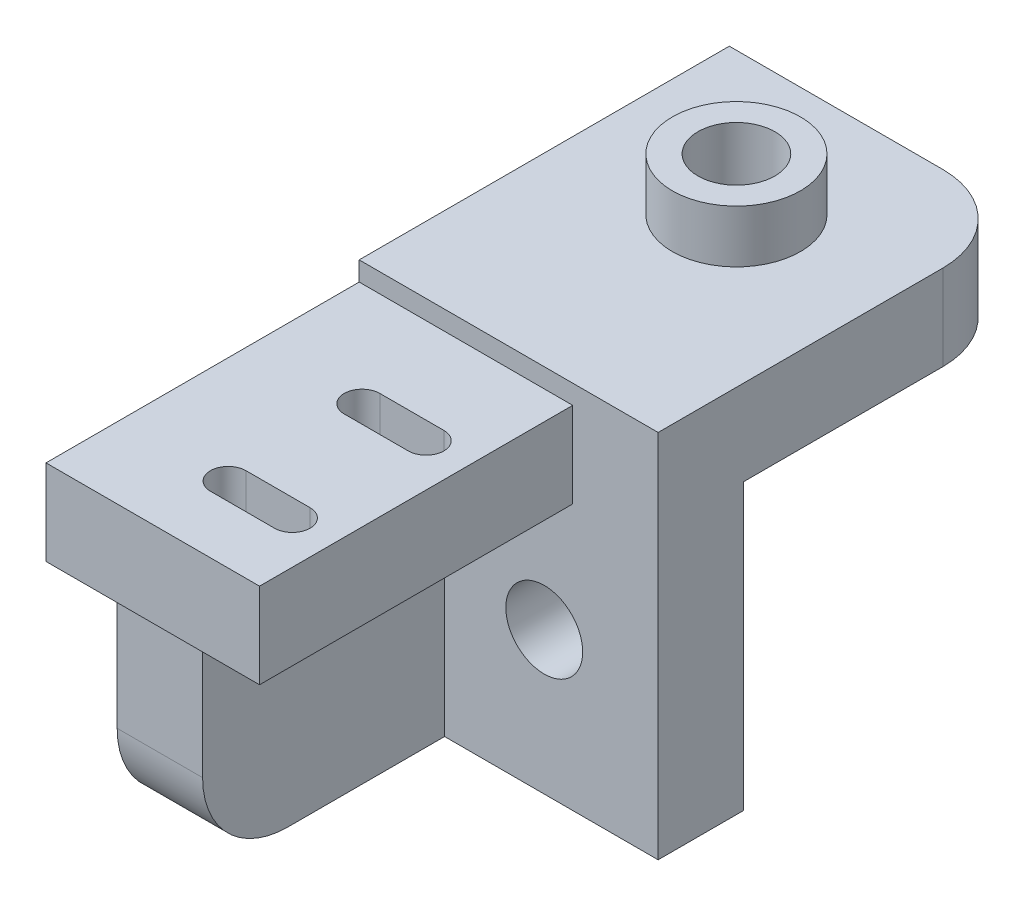
from build123d import *

# Parameters (mm, degrees)
SZKIC1_W                    = 21
SZKIC1_H                    = 6
SZKIC1_H_2                  = 20
SZKIC1_R                    = 2.7
DODANIE_WYCI_GNI_CIE1_DEPTH = 6
SZKIC2_W                    = 21
SZKIC2_H                    = 6
DODANIE_WYCI_GNI_CIE2_DEPTH = 20
SZKIC3_R                    = 2.7
WYTNIJ_WYCI_GNI_CIE1_DEPTH  = 9
SZKIC4_W                    = 15
SZKIC4_H                    = 6
DODANIE_WYCI_GNI_CIE3_DEPTH = 22
SZKIC8_R                    = 4.5
SZKIC8_R_2                  = 2.7
DODANIE_WYCI_GNI_CIE6_DEPTH = 3.7
SZKIC9_W                    = 6
SZKIC9_H                    = 18.65
DODANIE_WYCI_GNI_CIE7_DEPTH = 17
ZAOKR_GLENIE3_R             = 6
WYTNIJ_WYCI_GNI_CIE2_DEPTH  = 22
ZAOKR_GLENIE4_R             = 6
SZKIC6_R                    = 4.5
SZKIC6_R_2                  = 2.7
DODANIE_WYCI_GNI_CIE5_DEPTH = 3.7


with BuildPart() as part:
    # Szkic1 → Dodanie-wyciągnięcie1 (new body)
    with BuildSketch(Plane.XY):
        with Locations((10.5, 23)):
            Rectangle(SZKIC1_W, SZKIC1_H)
        with Locations((10.5, 10)):
            Rectangle(SZKIC1_W, SZKIC1_H_2)
        with Locations((13, 10)):
            Circle(SZKIC1_R, mode=Mode.SUBTRACT)
    extrude(amount=DODANIE_WYCI_GNI_CIE1_DEPTH)

    # Szkic2 → Dodanie-wyciągnięcie2 (add)
    with BuildSketch(Plane(origin=(0, 0, 0), x_dir=(-1, 0, 0), z_dir=(0, 0, -1))):
        with Locations((-10.5, 23)):
            Rectangle(SZKIC2_W, SZKIC2_H)
    extrude(amount=DODANIE_WYCI_GNI_CIE2_DEPTH)

    # Szkic3 → Wytnij-wyciągnięcie1 (cut)
    with BuildSketch(Plane(origin=(0, 26, 0), x_dir=(1, 0, 0), z_dir=(0, 1, 0))):
        with Locations((10.5, 10)):
            Circle(SZKIC3_R)
    extrude(amount=-WYTNIJ_WYCI_GNI_CIE1_DEPTH, mode=Mode.SUBTRACT)

    # Szkic4 → Dodanie-wyciągnięcie3 (add)
    with BuildSketch(Plane.XY.offset(6)):
        with Locations((7.5, 21.65)):
            Rectangle(SZKIC4_W, SZKIC4_H)
    extrude(amount=DODANIE_WYCI_GNI_CIE3_DEPTH)

    # Szkic8 → Dodanie-wyciągnięcie6 (add)
    with BuildSketch(Plane(origin=(0, 26, 0), x_dir=(1, 0, 0), z_dir=(0, 1, 0))):
        with Locations((10.5, 10)):
            Circle(SZKIC8_R)
        with Locations((10.5, 10)):
            Circle(SZKIC8_R_2, mode=Mode.SUBTRACT)
    extrude(amount=DODANIE_WYCI_GNI_CIE6_DEPTH)

    # Szkic9 → Dodanie-wyciągnięcie7 (add)
    with BuildSketch(Plane.XY.offset(6)):
        with Locations((3, 9.325)):
            Rectangle(SZKIC9_W, SZKIC9_H)
    extrude(amount=DODANIE_WYCI_GNI_CIE7_DEPTH)

    # Zaokrąglenie3
    zaokr_glenie3_edges = [part.edges().sort_by_distance(p)[0] for p in [
        (3, 0, 23),
    ]]
    fillet(zaokr_glenie3_edges, radius=ZAOKR_GLENIE3_R)

    # Szkic12 → Wytnij-wyciągnięcie2 (cut)
    with BuildSketch(Plane(origin=(0, 24.65, 0), x_dir=(1, 0, 0), z_dir=(0, 1, 0))):
        with BuildLine():
            Line((12, -14.55), (7.5, -14.55))
            ThreePointArc((7.5, -14.55), (6.25, -13.3), (7.5, -12.05))
            Line((7.5, -12.05), (12, -12.05))
            ThreePointArc((12, -12.05), (13.25, -13.3), (12, -14.55))
        make_face()
        with BuildLine():
            Line((12, -21.45), (7.5, -21.45))
            ThreePointArc((7.5, -21.45), (6.25, -22.7), (7.5, -23.95))
            Line((7.5, -23.95), (12, -23.95))
            ThreePointArc((12, -23.95), (13.25, -22.7), (12, -21.45))
        make_face()
    extrude(amount=-WYTNIJ_WYCI_GNI_CIE2_DEPTH, mode=Mode.SUBTRACT)

    # Zaokrąglenie4
    zaokr_glenie4_edges = [part.edges().sort_by_distance(p)[0] for p in [
        (21, 23, -20),
    ]]
    fillet(zaokr_glenie4_edges, radius=ZAOKR_GLENIE4_R)

    # Szkic6 → Dodanie-wyciągnięcie5 (add)
    with BuildSketch(Plane(origin=(0, 26, 0), x_dir=(1, 0, 0), z_dir=(0, 1, 0))):
        with Locations((10.5, 10)):
            Circle(SZKIC6_R)
        with Locations((10.5, 10)):
            Circle(SZKIC6_R_2, mode=Mode.SUBTRACT)
    extrude(amount=DODANIE_WYCI_GNI_CIE5_DEPTH)


solid = part.part
